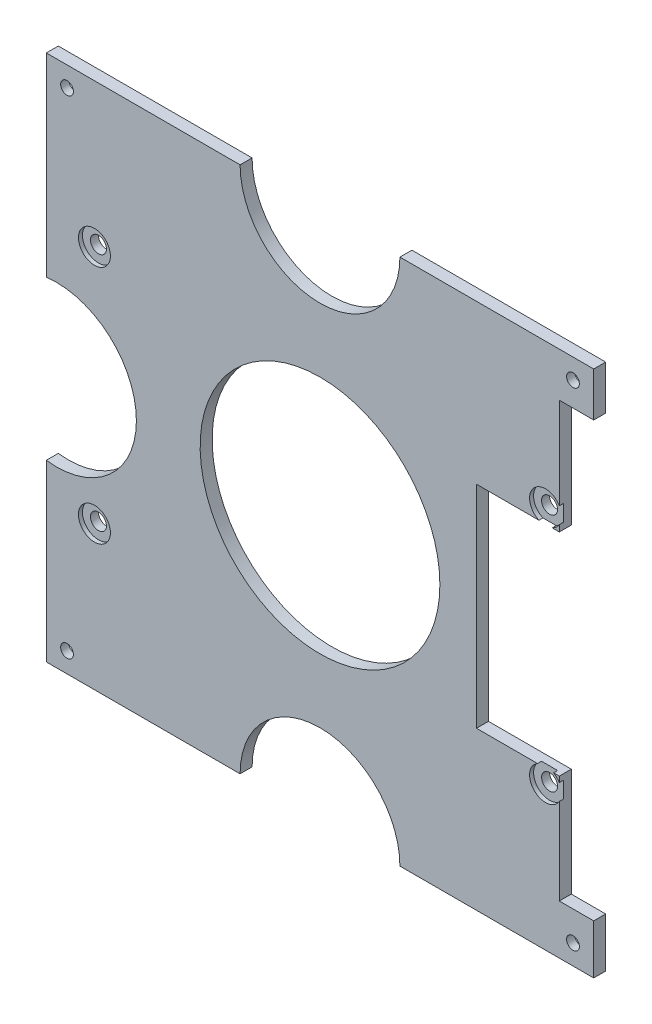
from build123d import *

# Parameters (mm, degrees)
SKETCH_1_R           = 1.6
EXTRUDE_1_DEPTH      = 6
SKETCH_2_R           = 30
CUT_EXTRUDE_1_DEPTH  = 13
SKETCH_3_R           = 3.5
CUT_EXTRUDE_2_DEPTH  = 3
SKETCH_5_R           = 2
CUT_EXTRUDE_3_DEPTH  = 23.5
SKETCH_6_R           = 4
CUT_EXTRUDE_4_DEPTH  = 2
CUT_EXTRUDE_6_REACH  = 134
SKETCH_8_W           = 137
SKETCH_8_H           = 2
CUT_EXTRUDE_7_REACH  = 139
SKETCH_9_W           = 1
SKETCH_9_H           = 132
SKETCH_10_W          = 29.336996967
SKETCH_10_H          = 52.898776648
CUT_EXTRUDE_11_DEPTH = 10
SKETCH_11_W          = 8.60940703
SKETCH_11_H          = 108.550160487
CUT_EXTRUDE_12_DEPTH = 10


with BuildPart() as part:
    # 草图1 → 凸台-拉伸1 (new body)
    with BuildSketch(Plane.XY):
        with BuildLine():
            Line((68.5, 66), (20, 66))
            ThreePointArc((20, 66), (0, 46), (-20, 66))
            Line((-20, 66), (-68.5, 66))
            Line((-68.5, 66), (-68.5, 17.384653731))
            ThreePointArc((-68.5, 17.384653731), (-52.74289675, 12.562504398), (-45.954411074, -2.452684221))
            ThreePointArc((-45.954411074, -2.452684221), (-52.74289675, -17.46787284), (-68.5, -22.290022173))
            Line((-68.5, -22.290022173), (-68.5, -66))
            Line((-68.5, -66), (-20, -66))
            ThreePointArc((-20, -66), (0, -46), (20, -66))
            Line((20, -66), (68.5, -66))
            Line((68.5, -66), (68.5, -17.384653731))
            ThreePointArc((68.5, -17.384653731), (45.954411074, 2.452684221), (68.5, 22.290022173))
            Line((68.5, 22.290022173), (68.5, 66))
        make_face()
        with Locations((-63.310606061, -61)):
            Circle(SKETCH_1_R, mode=Mode.SUBTRACT)
        with Locations((63.310606061, -61)):
            Circle(SKETCH_1_R, mode=Mode.SUBTRACT)
        with Locations((-63.310606061, 61)):
            Circle(SKETCH_1_R, mode=Mode.SUBTRACT)
        with Locations((63.310606061, 61)):
            Circle(SKETCH_1_R, mode=Mode.SUBTRACT)
    extrude(amount=EXTRUDE_1_DEPTH)

    # 草图2 → 切除-拉伸1 (cut)
    with BuildSketch(Plane.XY.offset(6)):
        Circle(SKETCH_2_R)
    extrude(amount=-CUT_EXTRUDE_1_DEPTH, mode=Mode.SUBTRACT)

    # 草图3 → 切除-拉伸2 (cut)
    with BuildSketch(Plane(origin=(0, 0, 0), x_dir=(-1, 0, 0), z_dir=(0, 0, -1))):
        with Locations((-63.310606061, 61)):
            Circle(SKETCH_3_R)
        with Locations((63.310606061, 61)):
            Circle(SKETCH_3_R)
        with Locations((-63.310606061, -61)):
            Circle(SKETCH_3_R)
        with Locations((63.310606061, -61)):
            Circle(SKETCH_3_R)
    extrude(amount=-CUT_EXTRUDE_2_DEPTH, mode=Mode.SUBTRACT)

    # 草图5 → 切除-拉伸3 (cut)
    with BuildSketch(Plane.XY.offset(6)):
        with Locations((56.45, 30)):
            Circle(SKETCH_5_R)
        with Locations((-56.45, 30)):
            Circle(SKETCH_5_R)
        with Locations((-56.45, -30)):
            Circle(SKETCH_5_R)
        with Locations((56.45, -30)):
            Circle(SKETCH_5_R)
    extrude(amount=-CUT_EXTRUDE_3_DEPTH, mode=Mode.SUBTRACT)

    # 草图6 → 切除-拉伸4 (cut)
    with BuildSketch(Plane.XY.offset(6)):
        with Locations((56.45, 30)):
            Circle(SKETCH_6_R)
        with Locations((56.45, -30)):
            Circle(SKETCH_6_R)
        with Locations((-56.45, -30)):
            Circle(SKETCH_6_R)
        with Locations((-56.45, 30)):
            Circle(SKETCH_6_R)
    extrude(amount=-CUT_EXTRUDE_4_DEPTH, mode=Mode.SUBTRACT)

    # 草图8 → 切除-拉伸6 (cut, up to next)
    with BuildSketch(Plane(origin=(0, 66, 0), x_dir=(1, 0, 0), z_dir=(0, 1, 0)), mode=Mode.PRIVATE) as cut_extrude_6_sk1:
        with Locations((0, -1)):
            Rectangle(SKETCH_8_W, SKETCH_8_H)
    cut_extrude_6_tool1 = extrude(cut_extrude_6_sk1.sketch, amount=-CUT_EXTRUDE_6_REACH, mode=Mode.PRIVATE) & part.part
    add(cut_extrude_6_tool1.solids().sort_by_distance((0, 66, 1))[0], mode=Mode.SUBTRACT)

    # 草图9 → 切除-拉伸7 (cut, up to next)
    with BuildSketch(Plane(origin=(68.5, 0, 0), x_dir=(0, 0, -1), z_dir=(1, 0, 0)), mode=Mode.PRIVATE) as cut_extrude_7_sk1:
        with Locations((-5.5, 0)):
            Rectangle(SKETCH_9_W, SKETCH_9_H)
    cut_extrude_7_tool1 = extrude(cut_extrude_7_sk1.sketch, amount=-CUT_EXTRUDE_7_REACH, mode=Mode.PRIVATE) & part.part
    add(cut_extrude_7_tool1.solids().sort_by_distance((68.5, 0, 5.5))[0], mode=Mode.SUBTRACT)

    # 草图10 → 切除-拉伸11 (cut)
    with BuildSketch(Plane.XY.offset(5)):
        with Locations((53.831501516, -0.092402659)):
            Rectangle(SKETCH_10_W, SKETCH_10_H)
    extrude(amount=-CUT_EXTRUDE_11_DEPTH, mode=Mode.SUBTRACT)

    # 草图11 → 切除-拉伸12 (cut)
    with BuildSketch(Plane.XY.offset(5)):
        with Locations((64.195296485, 0.655364597)):
            Rectangle(SKETCH_11_W, SKETCH_11_H)
    extrude(amount=-CUT_EXTRUDE_12_DEPTH, mode=Mode.SUBTRACT)


solid = part.part
